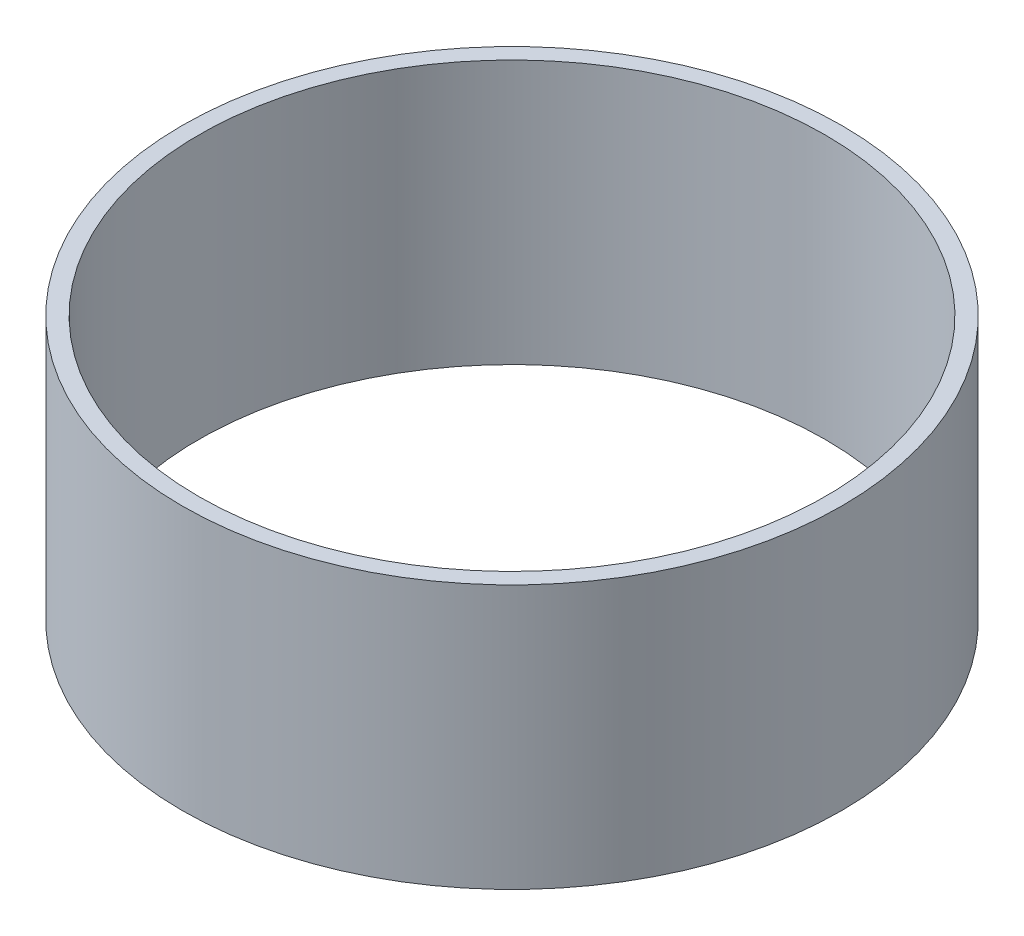
from build123d import *

# Parameters (mm, degrees)
SKETCH_1_R          = 700
EXTRUDE_1_DEPTH     = 560
SKETCH_2_R          = 665
CUT_EXTRUDE_1_DEPTH = 560


with BuildPart() as part:
    # 草图1 → 凸台-拉伸1 (new body)
    with BuildSketch(Plane(origin=(0, 0, 0), x_dir=(1, 0, 0), z_dir=(0, 1, 0))):
        Circle(SKETCH_1_R)
    extrude(amount=EXTRUDE_1_DEPTH)

    # 草图2 → 切除-拉伸1 (cut)
    with BuildSketch(Plane(origin=(0, 560, 0), x_dir=(1, 0, 0), z_dir=(0, 1, 0))):
        Circle(SKETCH_2_R)
    extrude(amount=-CUT_EXTRUDE_1_DEPTH, mode=Mode.SUBTRACT)


solid = part.part
